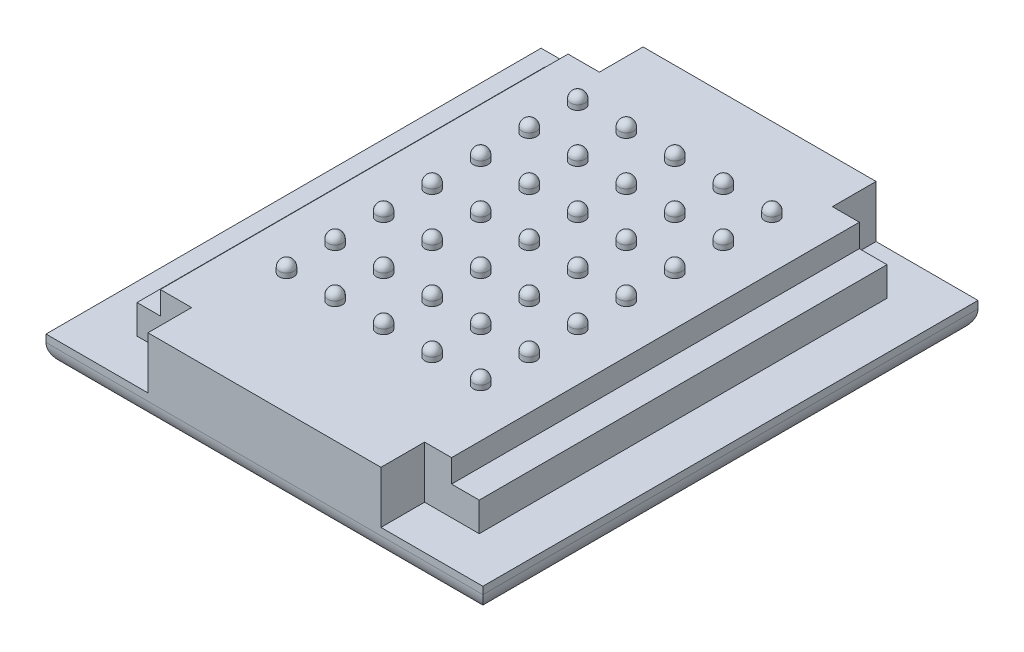
from build123d import *

# Parameters (mm, degrees)
SKETCH1_W           = 38.1
SKETCH1_H           = 43.18
BOSS_EXTRUDE1_DEPTH = 2.54
SKETCH2_W           = 29.845
SKETCH2_H           = 35.56
BOSS_EXTRUDE2_DEPTH = 2.54
SKETCH3_W           = 25.4
SKETCH3_H           = 35.56
BOSS_EXTRUDE3_DEPTH = 2
SKETCH5_R           = 0.635
BOSS_EXTRUDE4_DEPTH = 0.423333333
LPATTERN1_COUNT     = 5
LPATTERN1_PITCH     = 4.233333333
LPATTERN1_2_COUNT   = 7
LPATTERN1_2_PITCH   = 4.233333333
SKETCH7_W           = 20.32
SKETCH7_H           = 3.81
BOSS_EXTRUDE5_DEPTH = 4.54
FILLET1_R           = 1.905


with BuildPart() as part:
    # Sketch1 → Boss-Extrude1 (new body)
    with BuildSketch(Plane(origin=(0, 0, 0), x_dir=(1, 0, 0), z_dir=(0, 1, 0))):
        with Locations((-0.216477273, -10.297102273)):
            Rectangle(SKETCH1_W, SKETCH1_H)
    extrude(amount=BOSS_EXTRUDE1_DEPTH)

    # Sketch2 → Boss-Extrude2 (add)
    with BuildSketch(Plane(origin=(0, 2.54, 0), x_dir=(1, 0, 0), z_dir=(0, 1, 0))):
        with Locations((-0.216477273, -10.297102273)):
            Rectangle(SKETCH2_W, SKETCH2_H)
    extrude(amount=BOSS_EXTRUDE2_DEPTH)

    # Sketch3 → Boss-Extrude3 (add)
    with BuildSketch(Plane(origin=(0, 5.08, 0), x_dir=(1, 0, 0), z_dir=(0, 1, 0))):
        with Locations((-0.406977273, -10.297102273)):
            Rectangle(SKETCH3_W, SKETCH3_H)
    extrude(amount=BOSS_EXTRUDE3_DEPTH)

    # Sketch7 → Boss-Extrude5 (add)
    with BuildSketch(Plane(origin=(0, 2.54, 0), x_dir=(1, 0, 0), z_dir=(0, 1, 0))):
        with Locations((-0.216477273, -29.982102273)):
            Rectangle(SKETCH7_W, SKETCH7_H)
        with Locations((-0.216477273, 9.387897727)):
            Rectangle(SKETCH7_W, SKETCH7_H)
    extrude(amount=BOSS_EXTRUDE5_DEPTH)

    # Fillet1
    fillet1_edges = [part.edges().sort_by_distance(p)[0] for p in [
        (-0.216477273, 0, -11.292897727),
        (18.833522727, 0, 10.297102273),
        (-0.216477273, 0, 31.887102273),
        (-19.266477273, 0, 10.297102273),
    ]]
    fillet(fillet1_edges, radius=FILLET1_R)


with BuildPart() as body_2:
    # Sketch4 one side → Revolve6 (revolve)
    with BuildSketch(Plane(origin=(0, 7.08, 0), x_dir=(1, 0, 0), z_dir=(0, 1, 0))):
        with BuildLine():
            ThreePointArc((-8.873643939, 3.461239527), (-8.424631133, 3.647226721), (-8.238643939, 4.096239527))
            ThreePointArc((-8.238643939, 4.096239527), (-8.424631133, 4.545252333), (-8.873643939, 4.731239527))
            Line((-8.873643939, 4.731239527), (-8.873643939, 3.461239527))
        make_face()
    revolve(axis=Axis((-8.873643939, 7.08, -4.731239527), (0, 0, 1)))


with BuildPart() as body_2_1:
    # Body-Move/Copy2: moved
    add(body_2.part.moved(Location((0, 0.423333333, 0))))


with BuildPart() as body_3:
    # Sketch5 → Boss-Extrude4 (new body)
    with BuildSketch(Plane(origin=(0, 7.08, 0), x_dir=(1, 0, 0), z_dir=(0, 1, 0))):
        with Locations((-8.873643939, 4.096239527)):
            Circle(SKETCH5_R)
    extrude(amount=BOSS_EXTRUDE4_DEPTH)


with BuildPart() as body_2_2:
    add(body_2_1.part)

    # Combine1: union body 3
    add(body_3.part)


with BuildPart() as lpattern1_1:
    # LPattern1: pattern copy
    add(body_2_2.part.moved(Location(Vector(1, 0, 0) * (1 * LPATTERN1_PITCH))))


with BuildPart() as lpattern1_2:
    # LPattern1: pattern copy
    add(body_2_2.part.moved(Location(Vector(1, 0, 0) * (2 * LPATTERN1_PITCH))))


with BuildPart() as lpattern1_3:
    # LPattern1: pattern copy
    add(body_2_2.part.moved(Location(Vector(1, 0, 0) * (3 * LPATTERN1_PITCH))))


with BuildPart() as lpattern1_4:
    # LPattern1: pattern copy
    add(body_2_2.part.moved(Location(Vector(1, 0, 0) * (4 * LPATTERN1_PITCH))))


with BuildPart() as lpattern1_2_1:
    # LPattern1 2: pattern copy
    add(body_2_2.part.moved(Location(Vector(0, 0, 1) * (1 * LPATTERN1_2_PITCH))))


with BuildPart() as lpattern1_2_2:
    # LPattern1 2: pattern copy
    add(body_2_2.part.moved(Location(Vector(0, 0, 1) * (2 * LPATTERN1_2_PITCH))))


with BuildPart() as lpattern1_2_3:
    # LPattern1 2: pattern copy
    add(body_2_2.part.moved(Location(Vector(0, 0, 1) * (3 * LPATTERN1_2_PITCH))))


with BuildPart() as lpattern1_2_4:
    # LPattern1 2: pattern copy
    add(body_2_2.part.moved(Location(Vector(0, 0, 1) * (4 * LPATTERN1_2_PITCH))))


with BuildPart() as lpattern1_2_5:
    # LPattern1 2: pattern copy
    add(body_2_2.part.moved(Location(Vector(0, 0, 1) * (5 * LPATTERN1_2_PITCH))))


with BuildPart() as lpattern1_2_6:
    # LPattern1 2: pattern copy
    add(body_2_2.part.moved(Location(Vector(0, 0, 1) * (6 * LPATTERN1_2_PITCH))))


with BuildPart() as lpattern1_2_7:
    # LPattern1 2: pattern copy
    add(lpattern1_1.part.moved(Location(Vector(0, 0, 1) * (1 * LPATTERN1_2_PITCH))))


with BuildPart() as lpattern1_2_8:
    # LPattern1 2: pattern copy
    add(lpattern1_1.part.moved(Location(Vector(0, 0, 1) * (2 * LPATTERN1_2_PITCH))))


with BuildPart() as lpattern1_2_9:
    # LPattern1 2: pattern copy
    add(lpattern1_1.part.moved(Location(Vector(0, 0, 1) * (3 * LPATTERN1_2_PITCH))))


with BuildPart() as lpattern1_2_10:
    # LPattern1 2: pattern copy
    add(lpattern1_1.part.moved(Location(Vector(0, 0, 1) * (4 * LPATTERN1_2_PITCH))))


with BuildPart() as lpattern1_2_11:
    # LPattern1 2: pattern copy
    add(lpattern1_1.part.moved(Location(Vector(0, 0, 1) * (5 * LPATTERN1_2_PITCH))))


with BuildPart() as lpattern1_2_12:
    # LPattern1 2: pattern copy
    add(lpattern1_1.part.moved(Location(Vector(0, 0, 1) * (6 * LPATTERN1_2_PITCH))))


with BuildPart() as lpattern1_2_13:
    # LPattern1 2: pattern copy
    add(lpattern1_2.part.moved(Location(Vector(0, 0, 1) * (1 * LPATTERN1_2_PITCH))))


with BuildPart() as lpattern1_2_14:
    # LPattern1 2: pattern copy
    add(lpattern1_2.part.moved(Location(Vector(0, 0, 1) * (2 * LPATTERN1_2_PITCH))))


with BuildPart() as lpattern1_2_15:
    # LPattern1 2: pattern copy
    add(lpattern1_2.part.moved(Location(Vector(0, 0, 1) * (3 * LPATTERN1_2_PITCH))))


with BuildPart() as lpattern1_2_16:
    # LPattern1 2: pattern copy
    add(lpattern1_2.part.moved(Location(Vector(0, 0, 1) * (4 * LPATTERN1_2_PITCH))))


with BuildPart() as lpattern1_2_17:
    # LPattern1 2: pattern copy
    add(lpattern1_2.part.moved(Location(Vector(0, 0, 1) * (5 * LPATTERN1_2_PITCH))))


with BuildPart() as lpattern1_2_18:
    # LPattern1 2: pattern copy
    add(lpattern1_2.part.moved(Location(Vector(0, 0, 1) * (6 * LPATTERN1_2_PITCH))))


with BuildPart() as lpattern1_2_19:
    # LPattern1 2: pattern copy
    add(lpattern1_3.part.moved(Location(Vector(0, 0, 1) * (1 * LPATTERN1_2_PITCH))))


with BuildPart() as lpattern1_2_20:
    # LPattern1 2: pattern copy
    add(lpattern1_3.part.moved(Location(Vector(0, 0, 1) * (2 * LPATTERN1_2_PITCH))))


with BuildPart() as lpattern1_2_21:
    # LPattern1 2: pattern copy
    add(lpattern1_3.part.moved(Location(Vector(0, 0, 1) * (3 * LPATTERN1_2_PITCH))))


with BuildPart() as lpattern1_2_22:
    # LPattern1 2: pattern copy
    add(lpattern1_3.part.moved(Location(Vector(0, 0, 1) * (4 * LPATTERN1_2_PITCH))))


with BuildPart() as lpattern1_2_23:
    # LPattern1 2: pattern copy
    add(lpattern1_3.part.moved(Location(Vector(0, 0, 1) * (5 * LPATTERN1_2_PITCH))))


with BuildPart() as lpattern1_2_24:
    # LPattern1 2: pattern copy
    add(lpattern1_3.part.moved(Location(Vector(0, 0, 1) * (6 * LPATTERN1_2_PITCH))))


with BuildPart() as lpattern1_2_25:
    # LPattern1 2: pattern copy
    add(lpattern1_4.part.moved(Location(Vector(0, 0, 1) * (1 * LPATTERN1_2_PITCH))))


with BuildPart() as lpattern1_2_26:
    # LPattern1 2: pattern copy
    add(lpattern1_4.part.moved(Location(Vector(0, 0, 1) * (2 * LPATTERN1_2_PITCH))))


with BuildPart() as lpattern1_2_27:
    # LPattern1 2: pattern copy
    add(lpattern1_4.part.moved(Location(Vector(0, 0, 1) * (3 * LPATTERN1_2_PITCH))))


with BuildPart() as lpattern1_2_28:
    # LPattern1 2: pattern copy
    add(lpattern1_4.part.moved(Location(Vector(0, 0, 1) * (4 * LPATTERN1_2_PITCH))))


with BuildPart() as lpattern1_2_29:
    # LPattern1 2: pattern copy
    add(lpattern1_4.part.moved(Location(Vector(0, 0, 1) * (5 * LPATTERN1_2_PITCH))))


with BuildPart() as lpattern1_2_30:
    # LPattern1 2: pattern copy
    add(lpattern1_4.part.moved(Location(Vector(0, 0, 1) * (6 * LPATTERN1_2_PITCH))))


solid = Compound([part.part, body_2_2.part, lpattern1_1.part, lpattern1_2.part, lpattern1_3.part, lpattern1_4.part, lpattern1_2_1.part, lpattern1_2_2.part, lpattern1_2_3.part, lpattern1_2_4.part, lpattern1_2_5.part, lpattern1_2_6.part, lpattern1_2_7.part, lpattern1_2_8.part, lpattern1_2_9.part, lpattern1_2_10.part, lpattern1_2_11.part, lpattern1_2_12.part, lpattern1_2_13.part, lpattern1_2_14.part, lpattern1_2_15.part, lpattern1_2_16.part, lpattern1_2_17.part, lpattern1_2_18.part, lpattern1_2_19.part, lpattern1_2_20.part, lpattern1_2_21.part, lpattern1_2_22.part, lpattern1_2_23.part, lpattern1_2_24.part, lpattern1_2_25.part, lpattern1_2_26.part, lpattern1_2_27.part, lpattern1_2_28.part, lpattern1_2_29.part, lpattern1_2_30.part])
